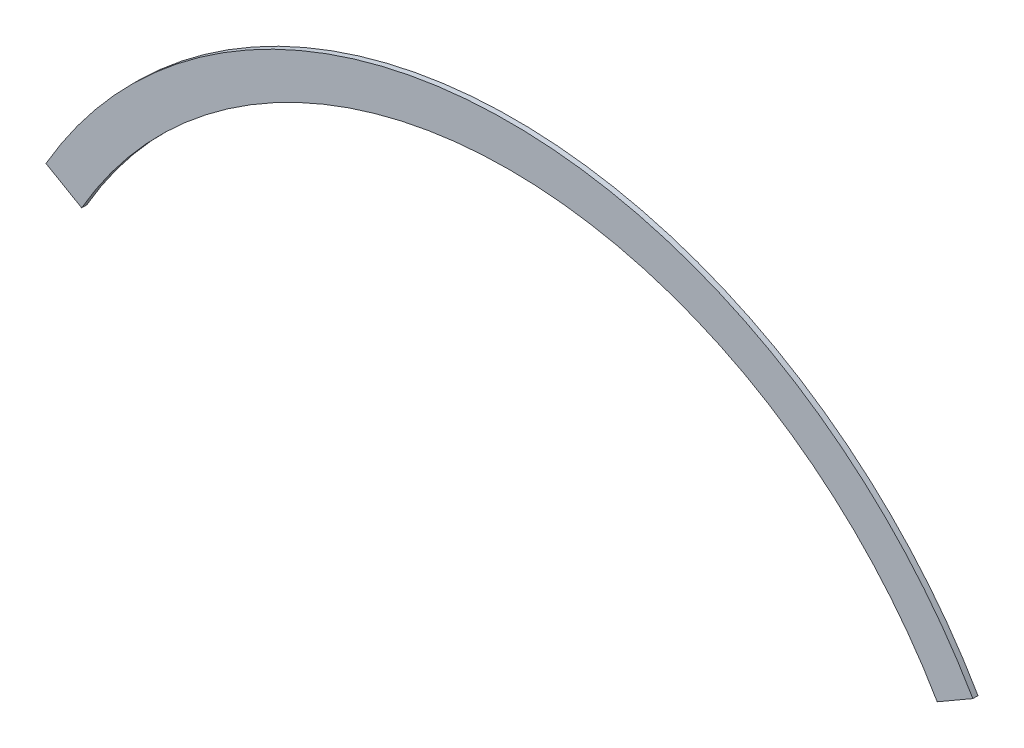
from build123d import *

# Parameters (mm, degrees)
BOSS_EXTRUDE1_DEPTH = 1.5875


with BuildPart() as part:
    # Sketch1 → Boss-Extrude1 (new body)
    with BuildSketch(Plane.XY):
        with BuildLine():
            Line((-142.980794165, 82.55), (-131.982271537, 76.2))
            ThreePointArc((-131.982271537, 76.2), (0, 152.4), (131.982271537, 76.2))
            Line((131.982271537, 76.2), (142.980794165, 82.55))
            ThreePointArc((142.980794165, 82.55), (0, 165.1), (-142.980794165, 82.55))
        make_face()
    extrude(amount=BOSS_EXTRUDE1_DEPTH)


solid = part.part
